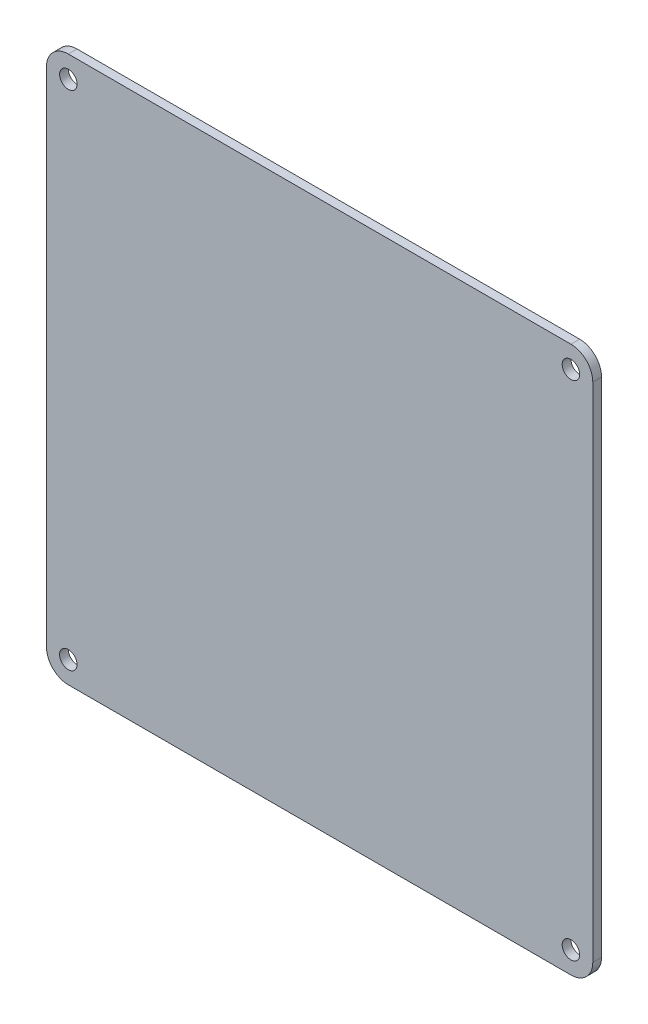
from build123d import *

# Parameters (mm, degrees)
SKETCH_1_R      = 1.6
EXTRUDE_1_DEPTH = 1.6


with BuildPart() as part:
    # 草图1 → 凸台-拉伸1 (new body)
    with BuildSketch(Plane.XY):
        with BuildLine():
            Line((-46, 50), (46, 50))
            ThreePointArc((46, 50), (48.828427125, 48.828427125), (50, 46))
            Line((50, 46), (50, -46))
            ThreePointArc((50, -46), (48.828427125, -48.828427125), (46, -50))
            Line((46, -50), (-46, -50))
            ThreePointArc((-46, -50), (-48.828427125, -48.828427125), (-50, -46))
            Line((-50, -46), (-50, 46))
            ThreePointArc((-50, 46), (-48.828427125, 48.828427125), (-46, 50))
        make_face()
        with Locations((46, 46)):
            Circle(SKETCH_1_R, mode=Mode.SUBTRACT)
        with Locations((46, -46)):
            Circle(SKETCH_1_R, mode=Mode.SUBTRACT)
        with Locations((-46, -46)):
            Circle(SKETCH_1_R, mode=Mode.SUBTRACT)
        with Locations((-46, 46)):
            Circle(SKETCH_1_R, mode=Mode.SUBTRACT)
    extrude(amount=EXTRUDE_1_DEPTH)


solid = part.part
